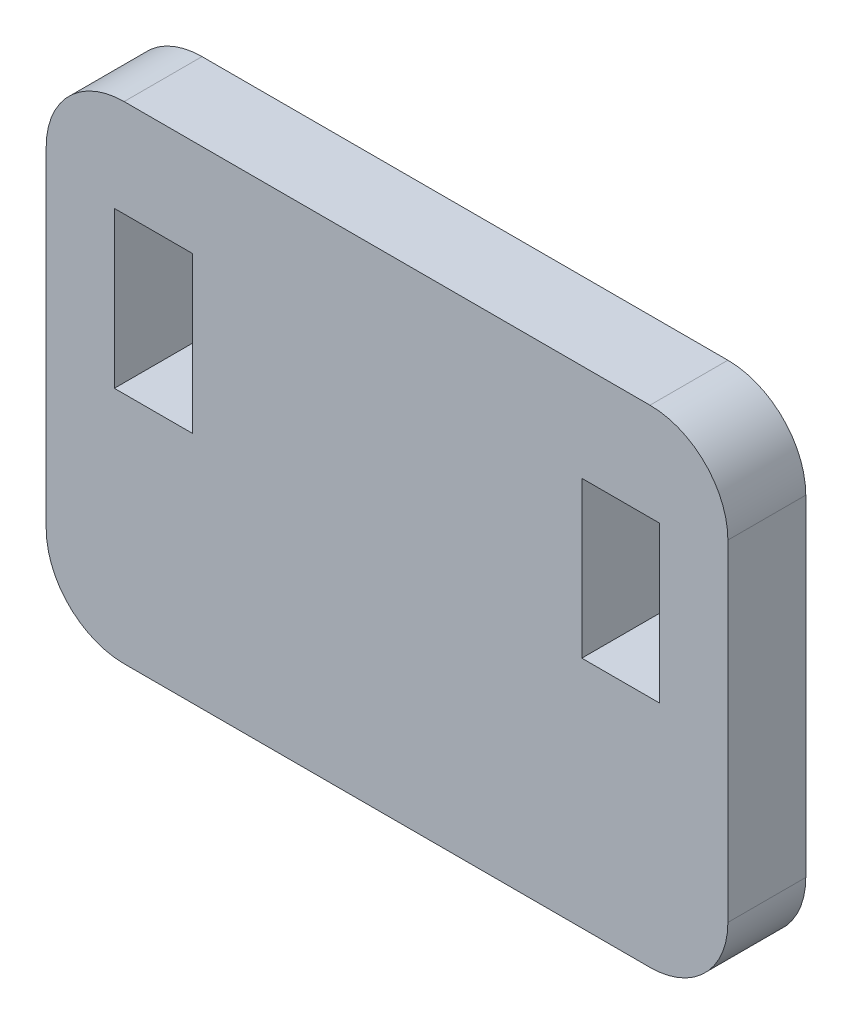
from build123d import *

# Parameters (mm, degrees)
SKETCH1_W           = 4
SKETCH1_H           = 8
BOSS_EXTRUDE1_DEPTH = 4


with BuildPart() as part:
    # Sketch1 → Boss-Extrude1 (new body)
    with BuildSketch(Plane.XY):
        with BuildLine():
            Line((4, 0), (31, 0))
            ThreePointArc((31, 0), (33.828427125, 1.171572875), (35, 4))
            Line((35, 4), (35, 21))
            ThreePointArc((35, 21), (33.828427125, 23.828427125), (31, 25))
            Line((31, 25), (4, 25))
            ThreePointArc((4, 25), (1.171572875, 23.828427125), (0, 21))
            Line((0, 21), (0, 4))
            ThreePointArc((0, 4), (1.171572875, 1.171572875), (4, 0))
        make_face()
        with Locations((5.5, 16)):
            Rectangle(SKETCH1_W, SKETCH1_H, mode=Mode.SUBTRACT)
        with Locations((29.5, 16)):
            Rectangle(SKETCH1_W, SKETCH1_H, mode=Mode.SUBTRACT)
    extrude(amount=BOSS_EXTRUDE1_DEPTH)


solid = part.part
